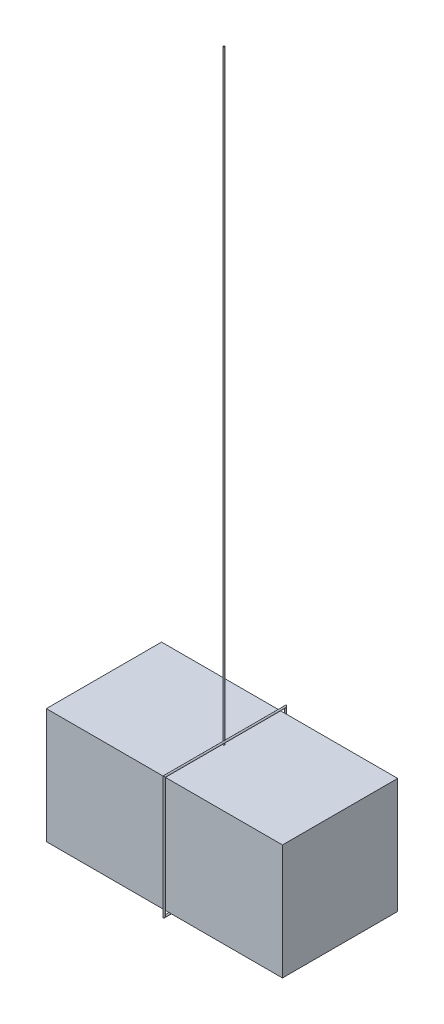
from build123d import *

# Parameters (mm, degrees)
SKETCH1_W                = 198.4375
SKETCH1_H                = 96.8375
EXTRUDE1_DEPTH           = 48.41875
ESBO_O2_R                = 0.714449934
ESBO_O3_R                = 0.635
RESSALTO_EXTRUS_O1_DEPTH = 508


with BuildPart() as part:
    # Sketch1 → Extrude1 (new body, symmetric)
    with BuildSketch(Plane.XY):
        with Locations((99.21875, -48.41875)):
            Rectangle(SKETCH1_W, SKETCH1_H)
    extrude(amount=EXTRUDE1_DEPTH, both=True)



with BuildPart() as body_2:
    # Varredura1: sweep along a path in Esboço1
    with BuildLine(Plane(origin=(101.6, 0, 0), x_dir=(0, 0, -1), z_dir=(1, 0, 0))) as varredura1_path:
        Line((-50.95875, 2.54), (50.95875, 2.54))
        Line((50.95875, 2.54), (50.95875, -99.3775))
        Line((50.95875, -99.3775), (-50.95875, -99.3775))
        Line((-50.95875, -99.3775), (-50.95875, 2.54))
    # Esboço2 → Varredura1 (sweep)
    with BuildSketch(Plane.XY):
        with Locations((101.6, 2.54)):
            Circle(ESBO_O2_R)
    sweep(path=varredura1_path.line, transition=Transition.RIGHT)


with BuildPart() as part_1:
    add(part.part)

    add(body_2.part)  # Ressalto-extrusão1 merges body 2
    # Esboço3 → Ressalto-extrusão1 (add)
    with BuildSketch(Plane(origin=(0, 0, 0), x_dir=(1, 0, 0), z_dir=(0, 1, 0))):
        with Locations((100.885550066, 0)):
            Circle(ESBO_O3_R)
    extrude(amount=RESSALTO_EXTRUS_O1_DEPTH)


solid = part_1.part
